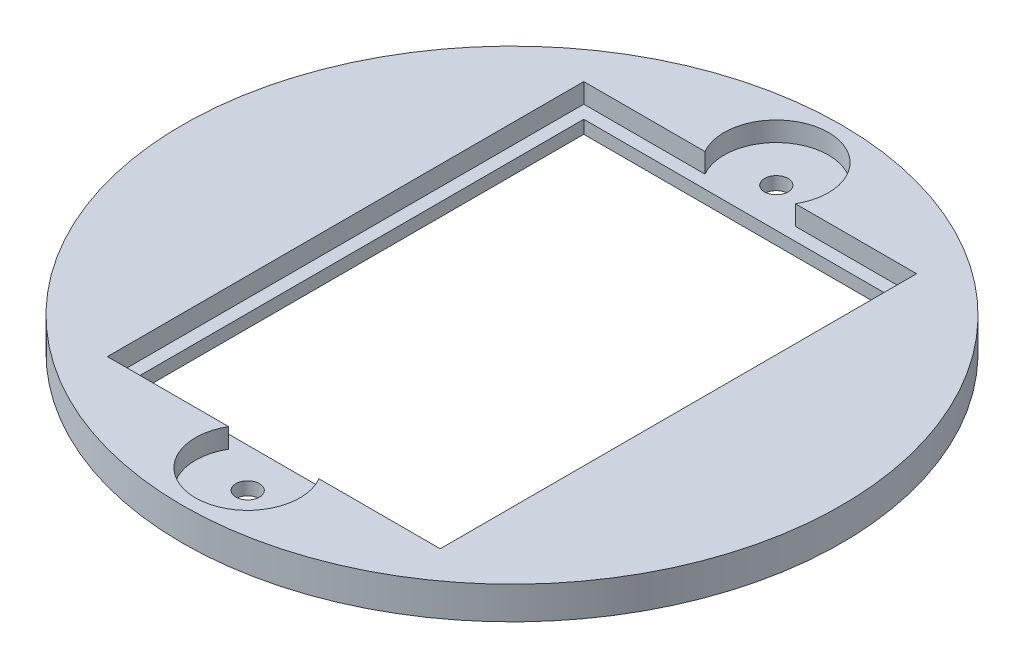
from build123d import *

# Parameters (mm, degrees)
SKETCH1_R           = 25.25
BOSS_EXTRUDE1_DEPTH = 2.5
SKETCH2_W           = 25.5
SKETCH2_H           = 36.5
CUT_EXTRUDE1_DEPTH  = 1.5
SKETCH3_W           = 23.5
SKETCH3_H           = 34.5
CUT_EXTRUDE2_DEPTH  = 1.2
SKETCH4_R           = 4
CUT_EXTRUDE3_DEPTH  = 1.5
SKETCH5_R           = 0.9
CUT_EXTRUDE4_DEPTH  = 2


with BuildPart() as part:
    # Sketch1 → Boss-Extrude1 (new body)
    with BuildSketch(Plane(origin=(0, 0, 0), x_dir=(1, 0, 0), z_dir=(0, 1, 0))):
        Circle(SKETCH1_R)
    extrude(amount=BOSS_EXTRUDE1_DEPTH)

    # Sketch2 → Cut-Extrude1 (cut)
    with BuildSketch(Plane(origin=(0, 2.5, 0), x_dir=(1, 0, 0), z_dir=(0, 1, 0))):
        Rectangle(SKETCH2_W, SKETCH2_H)
    extrude(amount=-CUT_EXTRUDE1_DEPTH, mode=Mode.SUBTRACT)

    # Sketch3 → Cut-Extrude2 (cut)
    with BuildSketch(Plane(origin=(0, 1, 0), x_dir=(1, 0, 0), z_dir=(0, 1, 0))):
        Rectangle(SKETCH3_W, SKETCH3_H)
    extrude(amount=-CUT_EXTRUDE2_DEPTH, mode=Mode.SUBTRACT)

    # Sketch4 → Cut-Extrude3 (cut)
    with BuildSketch(Plane(origin=(0, 2.5, 0), x_dir=(1, 0, 0), z_dir=(0, 1, 0))):
        with Locations((0, 20.25)):
            Circle(SKETCH4_R)
        with Locations((0, -20.25)):
            Circle(SKETCH4_R)
    extrude(amount=-CUT_EXTRUDE3_DEPTH, mode=Mode.SUBTRACT)

    # Sketch5 → Cut-Extrude4 (cut, through all)
    with BuildSketch(Plane(origin=(0, 1, 0), x_dir=(1, 0, 0), z_dir=(0, 1, 0))):
        with Locations((0, 20.25)):
            Circle(SKETCH5_R)
        with Locations((0, -20.25)):
            Circle(SKETCH5_R)
    extrude(amount=-CUT_EXTRUDE4_DEPTH, mode=Mode.SUBTRACT)


solid = part.part
